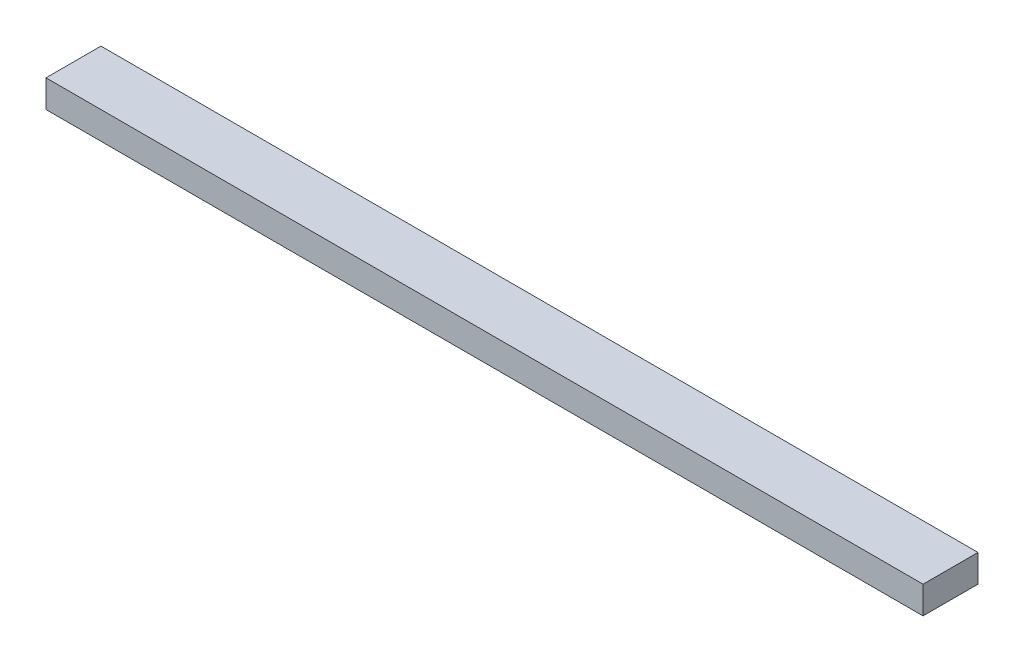
from build123d import *

# Parameters (mm, degrees)
SKETCH1_W           = 608.0125
SKETCH1_H           = 38.1
BOSS_EXTRUDE1_DEPTH = 19.05


with BuildPart() as part:
    # Sketch1 → Boss-Extrude1 (new body)
    with BuildSketch(Plane(origin=(0, 0, 0), x_dir=(1, 0, 0), z_dir=(0, 1, 0))):
        with Locations((304.00625, 19.05)):
            Rectangle(SKETCH1_W, SKETCH1_H)
    extrude(amount=BOSS_EXTRUDE1_DEPTH)


solid = part.part
